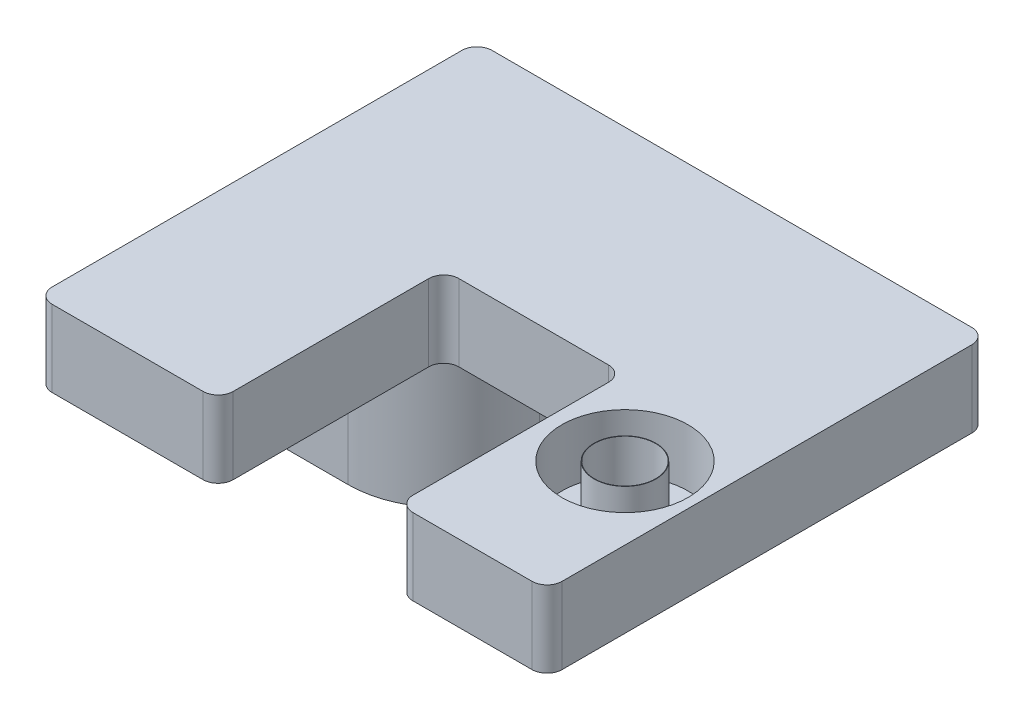
from build123d import *

# Parameters (mm, degrees)
SKETCH1_R           = 2.032
BOSS_EXTRUDE1_DEPTH = 5.08
FILLET2_R           = 1
SKETCH4_R           = 4.191
CUT_EXTRUDE3_DEPTH  = 3.81
SKETCH5_R           = 2.0574
SKETCH5_R_2         = 2.032
BOSS_EXTRUDE2_DEPTH = 3.81
BOSS_EXTRUDE3_DEPTH = 10.16


with BuildPart() as part:
    # Sketch1 → Boss-Extrude1 (new body)
    with BuildSketch(Plane(origin=(0, 0, 0), x_dir=(1, 0, 0), z_dir=(0, 1, 0))):
        Polygon((0, 29.21), (0, 0), (12.022666667, 0), (12.022666667, 14.986), (23.960666667, 14.986), (23.960666667, 0), (33.866666667, 0), (33.866666667, 29.21), align=None)
        with Locations((29.040666667, 10)):
            Circle(SKETCH1_R, mode=Mode.SUBTRACT)
    extrude(amount=BOSS_EXTRUDE1_DEPTH)

    # Fillet2
    fillet2_edges = [part.edges().sort_by_distance(p)[0] for p in [
        (23.960666667, 2.54, -14.986),
        (12.022666667, 2.54, -14.986),
        (12.022666667, 2.54, 0),
        (0, 2.54, 0),
        (0, 2.54, -29.21),
        (33.866666667, 2.54, -29.21),
        (33.866666667, 2.54, 0),
        (23.960666667, 2.54, 0),
    ]]
    fillet(fillet2_edges, radius=FILLET2_R)

    # Sketch4 → Cut-Extrude3 (cut)
    with BuildSketch(Plane(origin=(0, 5.08, 0), x_dir=(1, 0, 0), z_dir=(0, 1, 0))):
        with Locations((29.040666667, 10)):
            Circle(SKETCH4_R)
    extrude(amount=-CUT_EXTRUDE3_DEPTH, mode=Mode.SUBTRACT)

    # Sketch5 → Boss-Extrude2 (add)
    with BuildSketch(Plane(origin=(0, 1.27, 0), x_dir=(1, 0, 0), z_dir=(0, 1, 0))):
        with Locations((29.040666667, 10)):
            Circle(SKETCH5_R)
        with Locations((29.040666667, 10)):
            Circle(SKETCH5_R_2, mode=Mode.SUBTRACT)
    extrude(amount=BOSS_EXTRUDE2_DEPTH)

    # Sketch6 → Boss-Extrude3 (add)
    with BuildSketch(Plane.XZ):
        with BuildLine():
            Line((1, -29.21), (12.315559885, -29.21))
            Line((12.315559885, -29.21), (12.315559885, -21.043106781))
            ThreePointArc((12.315559885, -21.043106781), (10.455687946, -16.552978721), (5.965559885, -14.693106781))
            Line((5.965559885, -14.693106781), (0, -14.693106781))
            Line((0, -14.693106781), (0, -28.21))
            ThreePointArc((0, -28.21), (0.292893219, -28.917106781), (1, -29.21))
        make_face()
    extrude(amount=BOSS_EXTRUDE3_DEPTH)


solid = part.part
